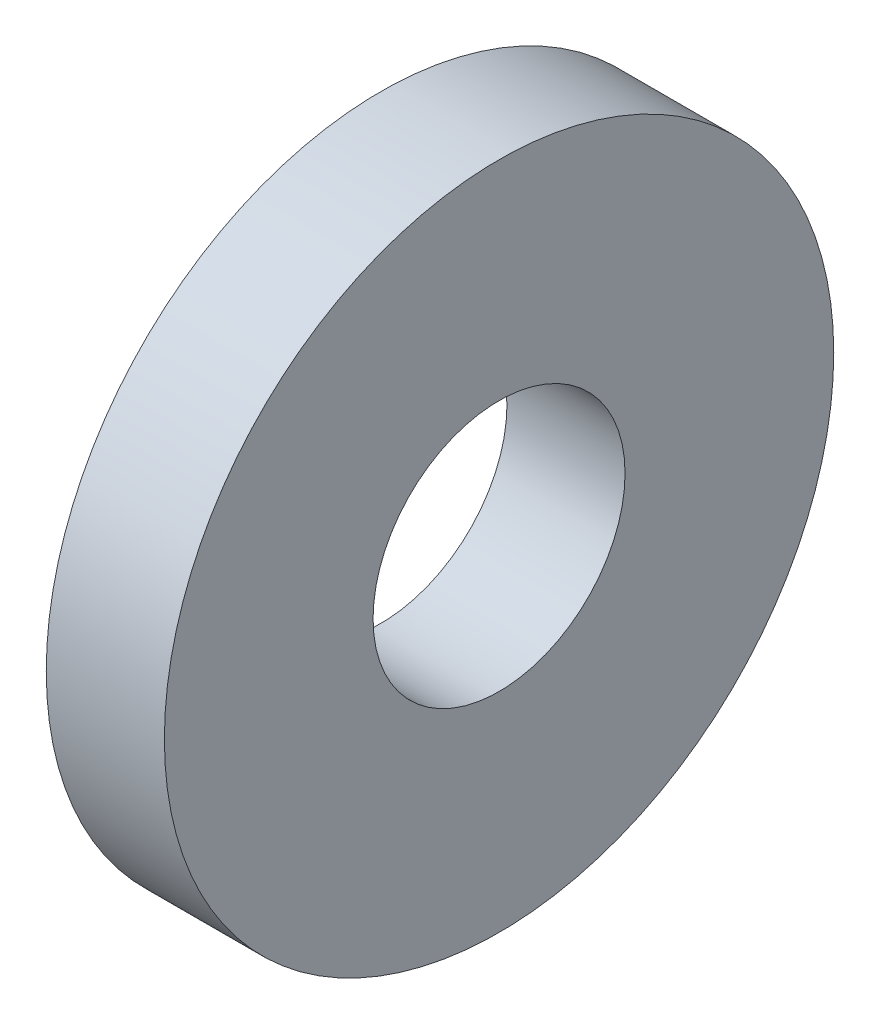
from build123d import *

# Parameters (mm, degrees)
SKETCH1_R          = 8.5
SKETCH1_R_2        = 3.2
BASE_EXTRUDE_DEPTH = 3


with BuildPart() as part:
    # Sketch1 → Base-Extrude (new body)
    with BuildSketch(Plane(origin=(0, 0, 0), x_dir=(0, 0, -1), z_dir=(1, 0, 0))):
        with Locations((0.573716632, -0.860574949)):
            Circle(SKETCH1_R)
        with Locations((0.573716632, -0.860574949)):
            Circle(SKETCH1_R_2, mode=Mode.SUBTRACT)
    extrude(amount=BASE_EXTRUDE_DEPTH)


solid = part.part
